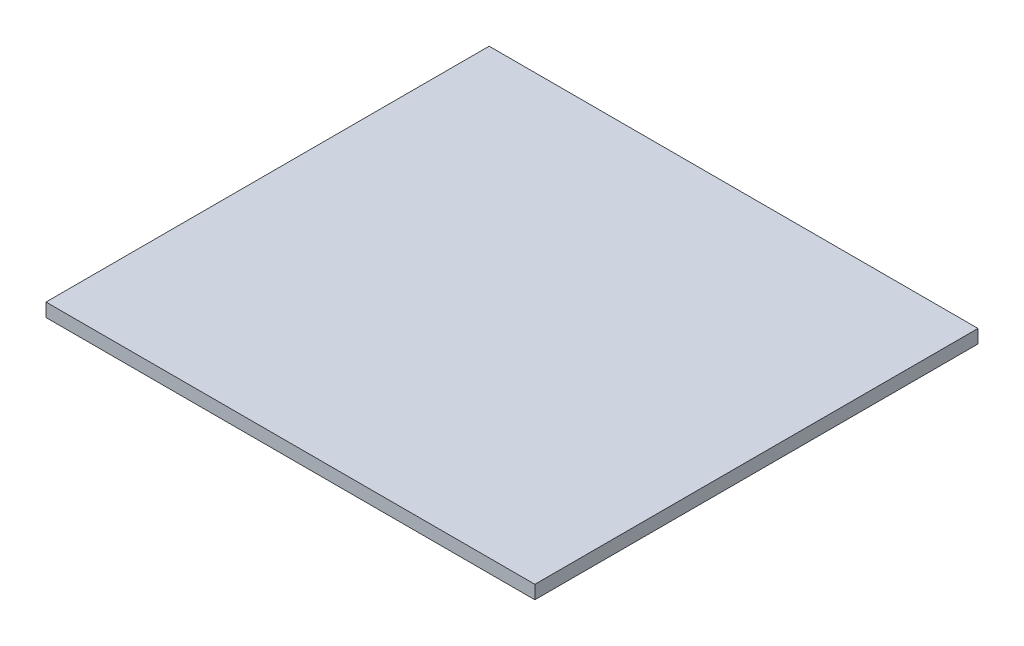
from build123d import *

# Parameters (mm, degrees)
SKETCH1_W           = 109
SKETCH1_H           = 98.8
BOSS_EXTRUDE1_DEPTH = 3


with BuildPart() as part:
    # Sketch1 → Boss-Extrude1 (new body)
    with BuildSketch(Plane(origin=(0, 0, 0), x_dir=(1, 0, 0), z_dir=(0, 1, 0))):
        with Locations((10.218457944, -28.701985981)):
            Rectangle(SKETCH1_W, SKETCH1_H)
    extrude(amount=BOSS_EXTRUDE1_DEPTH)


solid = part.part
